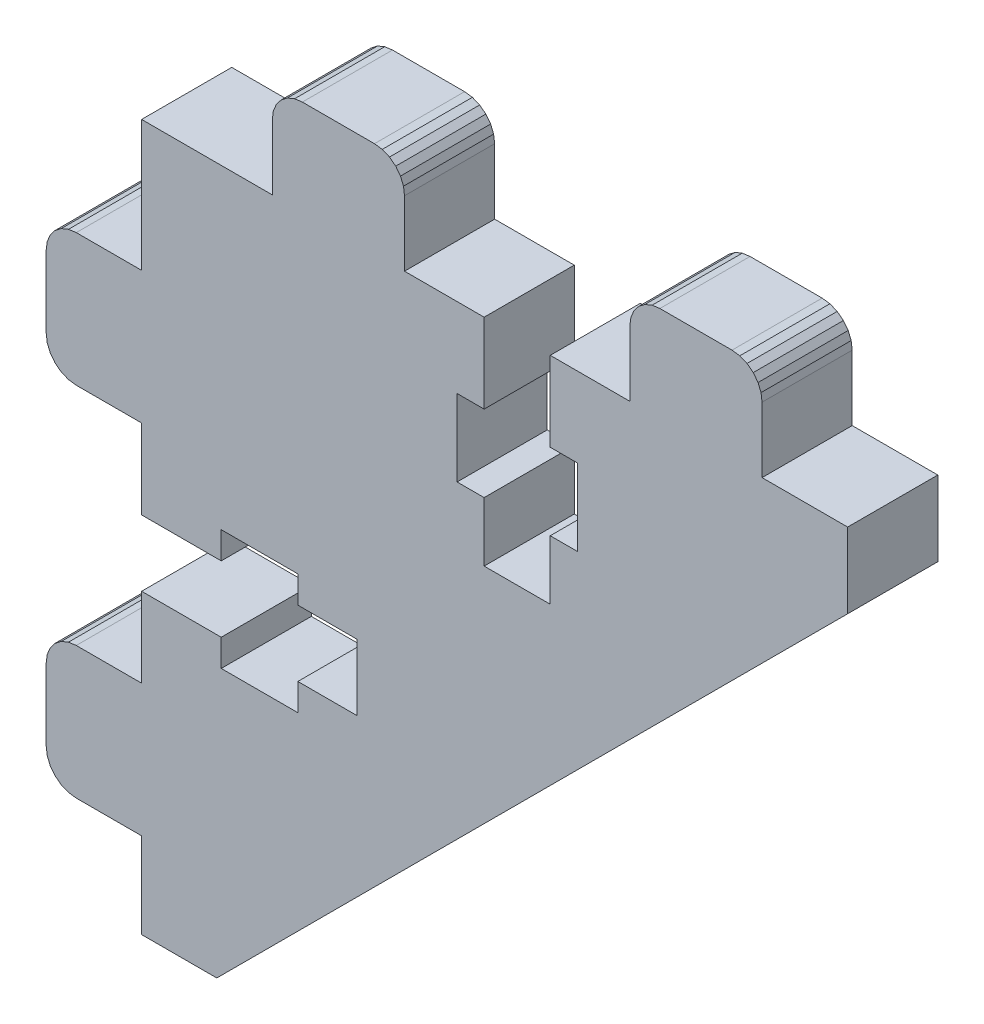
from build123d import *

# Parameters (mm, degrees)
RESSALTO_EXTRUS_O1_DEPTH = 6


with BuildPart() as part:
    # Model → Ressalto-extrusão1 (new body)
    with BuildSketch(Plane.XY):
        Polygon((37.969283539, 43.996209277), (41.919283362, 43.996209277), (41.919283362, 39.596204606), (37.969283539, 39.596204606), (37.969283539, 37.796206374), (32.869285775, 37.796206374), (32.869285775, 39.596204606), (27.569286953, 39.596204606), (27.569286953, 34.296207351), (23.219289062, 34.296207351), (22.701650972, 34.228059003), (22.219289062, 34.028258158), (21.8050755, 33.710420913), (21.487238254, 33.296207351), (21.287437409, 32.813845441), (21.219289062, 32.296207351), (21.219289062, 27.496212909), (21.287437409, 26.978574818), (21.487238254, 26.496212909), (21.8050755, 26.081999346), (22.219289062, 25.764162101), (22.701650972, 25.564361256), (23.219289062, 25.496212909), (27.569286953, 25.496212909), (27.569286953, 19.803247953), (32.573283526, 19.803247953), (74.566390822, 61.794924044), (74.566390822, 66.796199314), (68.869269338, 66.796199314), (68.869269338, 71.146197205), (68.80112099, 71.663835295), (68.601320145, 72.146197205), (68.2834829, 72.560410768), (67.869269338, 72.878248013), (67.386907428, 73.078048858), (66.869269338, 73.146197205), (62.069273373, 73.146197205), (61.551635282, 73.078048858), (61.069273373, 72.878248013), (60.65505981, 72.560410768), (60.337222565, 72.146197205), (60.13742172, 71.663835295), (60.069273373, 71.146197205), (60.069273373, 66.796199314), (54.769281366, 66.796199314), (54.769281366, 61.496200492), (56.569279598, 61.496200492), (56.569279598, 56.396202728), (54.769281366, 56.396202728), (54.769281366, 52.446202905), (50.369276694, 52.446202905), (50.369276694, 56.396202728), (48.569278462, 56.396202728), (48.569278462, 61.496200492), (50.369276694, 61.496200492), (50.369276694, 66.796199314), (45.069279439, 66.796199314), (45.069279439, 71.146197205), (45.001131092, 71.663835295), (44.801330247, 72.146197205), (44.483493001, 72.560410768), (44.069279439, 72.878248013), (43.586917529, 73.078048858), (43.069279439, 73.146197205), (38.269284997, 73.146197205), (37.751646907, 73.078048858), (37.269284997, 72.878248013), (36.855071435, 72.560410768), (36.537234189, 72.146197205), (36.337433344, 71.663835295), (36.269284997, 71.146197205), (36.269284997, 66.796199314), (27.569286953, 66.796199314), (27.569286953, 58.096197249), (23.219289062, 58.096197249), (22.701650972, 58.028048902), (22.219289062, 57.828248057), (21.8050755, 57.510410812), (21.487238254, 57.096197249), (21.287437409, 56.613835339), (21.219289062, 56.096197249), (21.219289062, 51.296201284), (21.287437409, 50.778563194), (21.487238254, 50.296201284), (21.8050755, 49.881987722), (22.219289062, 49.564150477), (22.701650972, 49.364349632), (23.219289062, 49.296201284), (27.569286953, 49.296201284), (27.569286953, 43.996209277), (32.869285775, 43.996209277), (32.869285775, 45.796207509), (37.969283539, 45.796207509), align=None)
    extrude(amount=RESSALTO_EXTRUS_O1_DEPTH)


solid = part.part
